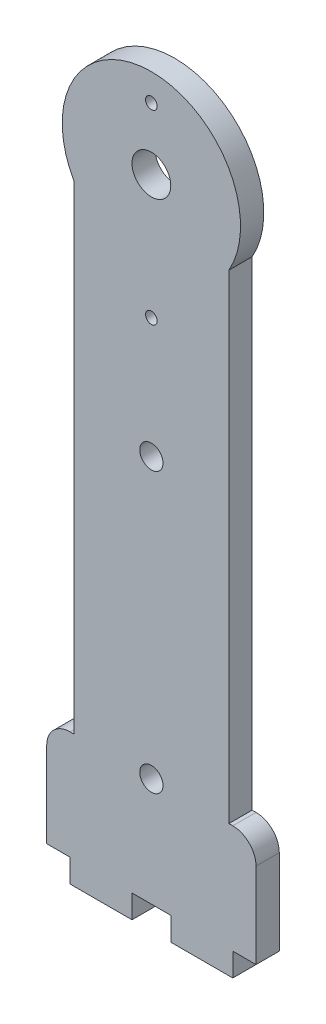
from build123d import *

# Parameters (mm, degrees)
CROQUIS1_R              = 11.5
CROQUIS1_W              = 20
CROQUIS1_H              = 67.5
CROQUIS1_W_2            = 27
CROQUIS1_H_2            = 14
SALIENTE_EXTRUIR1_DEPTH = 3
CROQUIS2_R              = 2.5
CROQUIS2_R_2            = 1.5
CORTAR_EXTRUIR1_DEPTH   = 4
REDONDEO1_R             = 3
CROQUIS3_R              = 0.75
CORTAR_EXTRUIR2_DEPTH   = 4
CROQUIS4_W              = 8
CROQUIS4_H              = 3
SALIENTE_EXTRUIR2_DEPTH = 3


with BuildPart() as part:
    # Croquis1 → Saliente-Extruir1 (new body)
    with BuildSketch(Plane.XY):
        Circle(CROQUIS1_R)
        with Locations((0, -33.75)):
            Rectangle(CROQUIS1_W, CROQUIS1_H)
        with Locations((0, -74.5)):
            Rectangle(CROQUIS1_W_2, CROQUIS1_H_2)
    extrude(amount=SALIENTE_EXTRUIR1_DEPTH)

    # Croquis2 → Cortar-Extruir1 (cut, through all)
    with BuildSketch(Plane.XY.offset(3)):
        Circle(CROQUIS2_R)
        with Locations((0, -31.5)):
            Circle(CROQUIS2_R_2)
        with Locations((0, -67.5)):
            Circle(CROQUIS2_R_2)
    extrude(amount=-CORTAR_EXTRUIR1_DEPTH, mode=Mode.SUBTRACT)

    # Redondeo1
    redondeo1_edges = [part.edges().sort_by_distance(p)[0] for p in [
        (13.5, -67.5, 1.5),
        (-13.5, -67.5, 1.5),
    ]]
    fillet(redondeo1_edges, radius=REDONDEO1_R)

    # Croquis3 → Cortar-Extruir2 (cut, through all)
    with BuildSketch(Plane.XY.offset(3)):
        with Locations((0, -16)):
            Circle(CROQUIS3_R)
        with Locations((0, 8)):
            Circle(CROQUIS3_R)
    extrude(amount=-CORTAR_EXTRUIR2_DEPTH, mode=Mode.SUBTRACT)

    # Croquis4 → Saliente-Extruir2 (add)
    with BuildSketch(Plane.XY.offset(3)):
        with Locations((-6.5, -83)):
            Rectangle(CROQUIS4_W, CROQUIS4_H)
        with Locations((6.5, -83)):
            Rectangle(CROQUIS4_W, CROQUIS4_H)
    extrude(amount=-SALIENTE_EXTRUIR2_DEPTH)


solid = part.part
